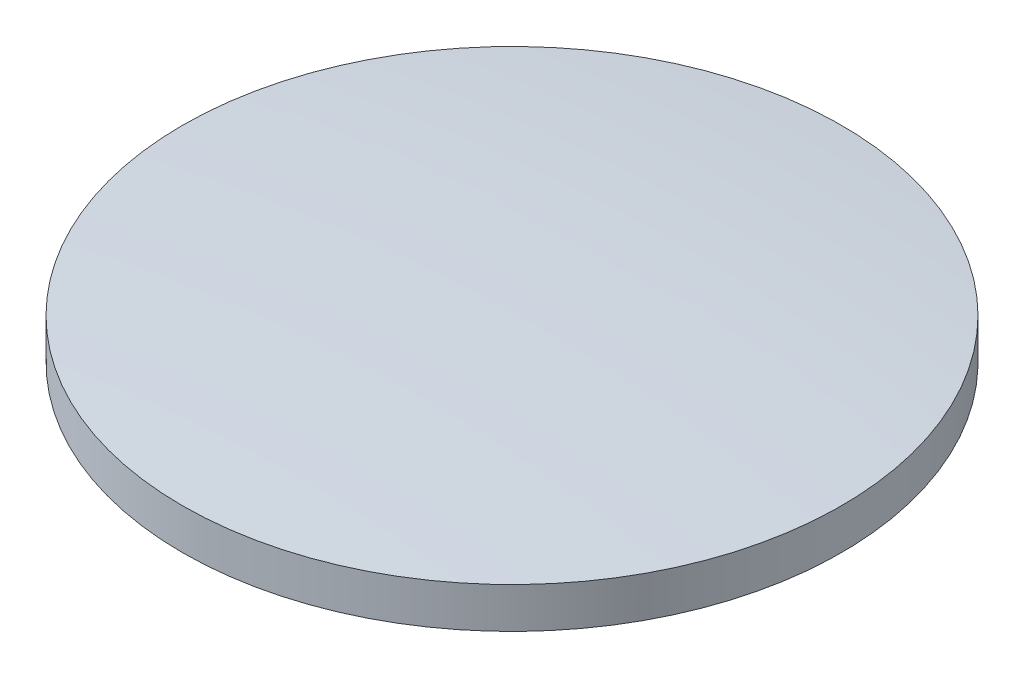
from build123d import *


with BuildPart() as part:
    # Sketch1 → Revolve1 (revolve)
    with BuildSketch(Plane.XY):
        with BuildLine():
            Line((0, 0), (-25.95, 0))
            Line((-25.95, 0), (-25.95, 3.2))
            ThreePointArc((-25.95, 3.2), (-12.988865424, 4.099839792), (0, 4.4))
            Line((0, 4.4), (0, 3.2))
            Line((0, 3.2), (0, 0))
        make_face()
    revolve(axis=Axis((0, 3.2, 0), (0, -1, 0)))


solid = part.part
